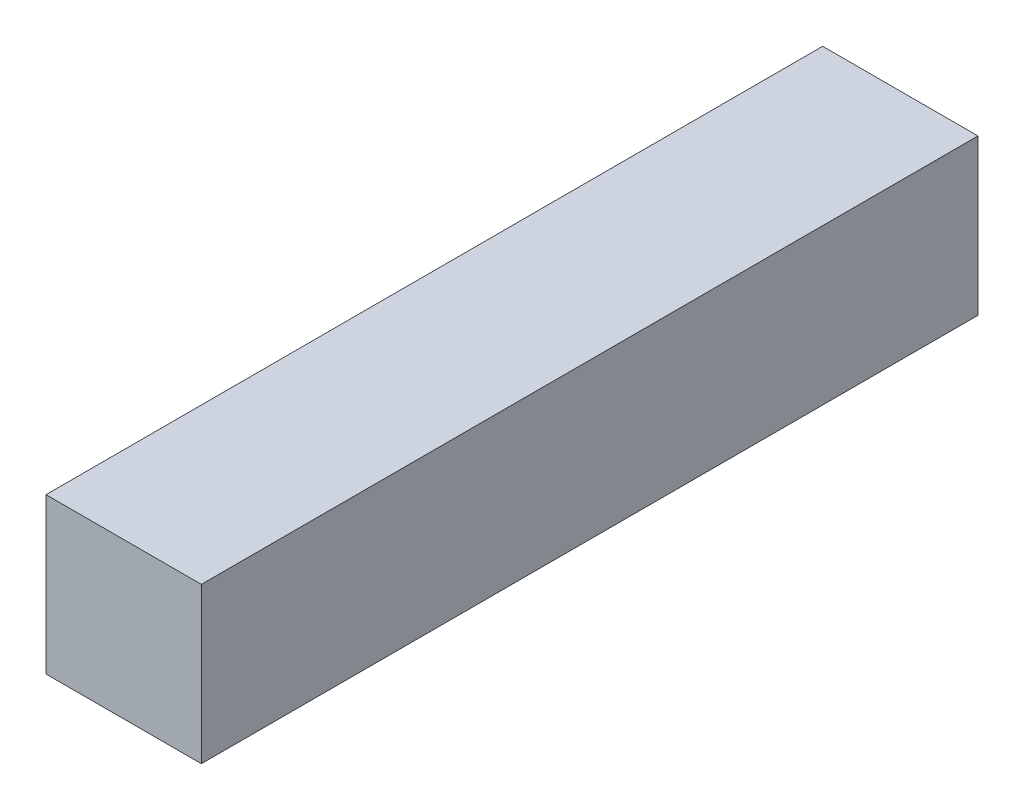
from build123d import *

# Parameters (mm, degrees)
SKETCH1_W           = 5.08
SKETCH1_H           = 25.4
BOSS_EXTRUDE1_DEPTH = 5.08


with BuildPart() as part:
    # Sketch1 → Boss-Extrude1 (new body)
    with BuildSketch(Plane(origin=(0, 0, 0), x_dir=(1, 0, 0), z_dir=(0, 1, 0))):
        Rectangle(SKETCH1_W, SKETCH1_H)
    extrude(amount=BOSS_EXTRUDE1_DEPTH)


solid = part.part
